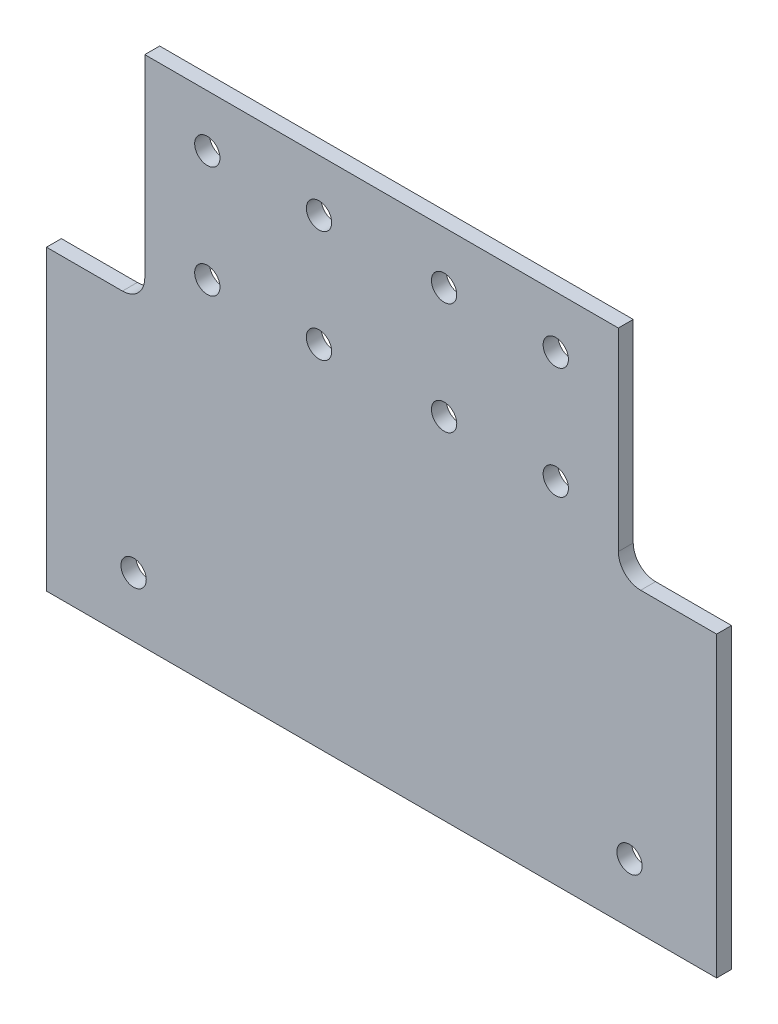
from build123d import *

# Parameters (mm, degrees)
BASE_PLATE_DEPTH     = 2
M3_CLEARANCE_HOLE1_D = 3.4
FILLET1_R            = 3


with BuildPart() as part:
    # Sketch1 → Base Plate (new body)
    with BuildSketch(Plane.XY):
        Polygon((31.8, 0), (-31.8, 0), (-31.8, -29), (-45, -29), (-45, -69), (45, -69), (45, -29), (31.8, -29), align=None)
    extrude(amount=BASE_PLATE_DEPTH)

    # M3 Clearance Hole1 (through all)
    with Locations(Plane.XY.offset(2)):
        with Locations((-23.4, -7), (-8.4, -7), (-8.4, -22), (-23.4, -22), (-33.3, -61), (33.3, -61), (8.4, -22), (23.4, -22), (8.4, -7), (23.4, -7)):
            Hole(M3_CLEARANCE_HOLE1_D / 2)

    # Fillet1
    fillet1_edges = [part.edges().sort_by_distance(p)[0] for p in [
        (31.8, -29, 1),
        (-31.8, -29, 1),
    ]]
    fillet(fillet1_edges, radius=FILLET1_R)


solid = part.part
